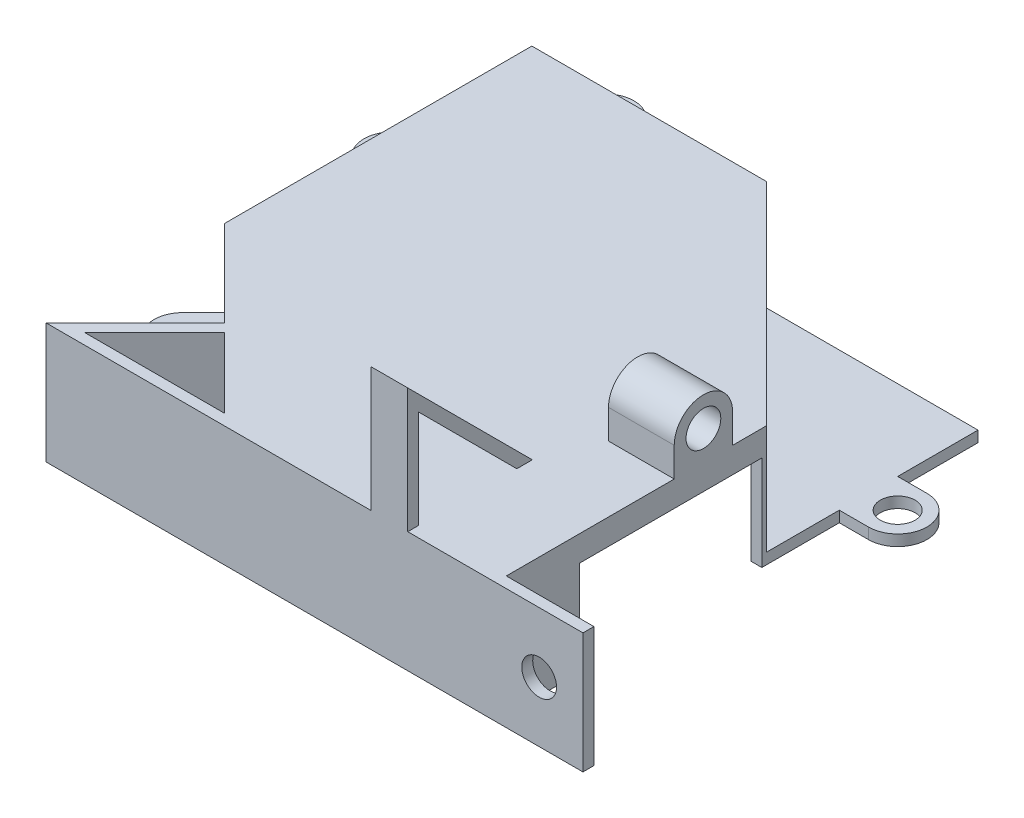
from build123d import *

# Parameters (mm, degrees)
SKETCH1_W            = 38
SKETCH1_H            = 1.5
SKETCH1_W_2          = 1.5
SKETCH1_H_2          = 32
SKETCH1_W_3          = 30
SKETCH1_H_3          = 40
BOSS_EXTRUDE1_DEPTH  = 15
BOSS_EXTRUDE2_DEPTH  = 1.5
SKETCH7_W            = 22
SKETCH7_H            = 12
BOSS_EXTRUDE4_DEPTH  = 10.5
SKETCH9_W            = 12.5
SKETCH9_H            = 8.5
CUT_EXTRUDE10_DEPTH  = 4.5
BOSS_EXTRUDE6_DEPTH  = 1.5
EXTRUDE_THIN1_START  = -20
EXTRUDE_THIN1_DEPTH  = 5
SKETCH16_W           = 10.5
SKETCH16_H           = 12
CUT_EXTRUDE15_DEPTH  = 35.121320344
BOSS_EXTRUDE10_DEPTH = 16
CUT_EXTRUDE16_DEPTH  = 34.560660172
SKETCH21_W           = 1.5
SKETCH21_H           = 25
CUT_EXTRUDE17_DEPTH  = 13
SKETCH25_W           = 1.5
SKETCH25_H           = 16.5
BOSS_EXTRUDE13_DEPTH = 12
BOSS_EXTRUDE14_DEPTH = 9
SKETCH27_R           = 2.38125
CUT_EXTRUDE18_DEPTH  = 6.35
SKETCH29_R           = 2.38125
CUT_EXTRUDE19_DEPTH  = 2.5
BOSS_EXTRUDE15_DEPTH = 9
BOSS_EXTRUDE16_DEPTH = 9
BOSS_EXTRUDE17_DEPTH = 9
BOSS_EXTRUDE18_DEPTH = 1.5
SKETCH34_R           = 2.38125
CUT_EXTRUDE20_DEPTH  = 34.560660172
SKETCH35_R           = 2.38125
CUT_EXTRUDE21_DEPTH  = 6.35


with BuildPart() as part:
    # Sketch1 → Boss-Extrude1 (new body)
    with BuildSketch(Plane(origin=(0, 0, 0), x_dir=(1, 0, 0), z_dir=(0, 1, 0))):
        Polygon((23.112698372, -23.112698372), (0, 0), (-1.060660172, -1.060660172), (10.2760191, -12.397339444), (11.408080409, -13.529400753), (20.991378029, -23.112698372), (22.0520382, -24.173358544), align=None)
        Polygon((23.112698372, -24.612698372), (23.112698372, -23.112698372), (22.0520382, -24.173358544), (22.491378029, -24.612698372), align=None)
        with Locations((42.112698372, -23.862698372)):
            Rectangle(SKETCH1_W, SKETCH1_H)
        with Locations((61.862698372, -23.862698372)):
            Rectangle(SKETCH1_W_2, SKETCH1_H)
        with Locations((61.862698372, -7.112698372)):
            Rectangle(SKETCH1_W_2, SKETCH1_H_2)
        Polygon((62.173358544, 9.9479618), (61.112698372, 8.887301628), (62.612698372, 8.887301628), (62.612698372, 9.508621971), align=None)
        Polygon((31.060660172, 41.060660172), (30, 40), (61.112698372, 8.887301628), (62.173358544, 9.9479618), align=None)
        Polygon((30, 41.5), (30, 40), (31.060660172, 41.060660172), (30.621320344, 41.5), align=None)
        with Locations((15, 40.75)):
            Rectangle(SKETCH1_W_3, SKETCH1_H)
        with Locations((-0.75, 40.75)):
            Rectangle(SKETCH1_W_2, SKETCH1_H)
        with Locations((-0.75, 20)):
            Rectangle(SKETCH1_W_2, SKETCH1_H_3)
        Polygon((-1.060660172, -1.060660172), (0, 0), (-1.5, 0), (-1.5, -0.621320344), align=None)
        Polygon((22.491378029, -24.612698372), (22.0520382, -24.173358544), (20.991378029, -23.112698372), (1.824782789, -23.112698372), (11.408080409, -13.529400753), (10.2760191, -12.397339444), (-1.939339828, -24.612698372), align=None)
    extrude(amount=BOSS_EXTRUDE1_DEPTH)

    # Sketch2 → Boss-Extrude2 (add)
    with BuildSketch(Plane(origin=(0, 15, 0), x_dir=(1, 0, 0), z_dir=(0, 1, 0))):
        Polygon((30.621320344, 41.5), (-1.5, 41.5), (-1.5, -0.621320344), (10.2760191, -12.397339444), (11.408080409, -13.529400753), (20.991378029, -23.112698372), (22.491378029, -24.612698372), (62.612698372, -24.612698372), (62.612698372, 9.508621971), align=None)
        Polygon((0, 40), (30, 40), (61.112698372, 8.887301628), (61.112698372, -23.112698372), (23.112698372, -23.112698372), (0, 0), align=None, mode=Mode.SUBTRACT)
        Polygon((30, 40), (61.112698372, 8.887301628), (61.112698372, -23.112698372), (23.112698372, -23.112698372), (0, 0), (0, 40), align=None)
        Polygon((11.408080409, -13.529400753), (10.2760191, -12.397339444), (-1.939339828, -24.612698372), (19.481361537, -24.612698372), (22.491378029, -24.612698372), (20.991378029, -23.112698372), (1.824782789, -23.112698372), align=None)
    extrude(amount=BOSS_EXTRUDE2_DEPTH)

    # Sketch7 → Boss-Extrude4 (add)
    with BuildSketch(Plane(origin=(62.612698372, 0, 0), x_dir=(0, 0, -1), z_dir=(1, 0, 0))):
        with Locations((-1.491378029, 6)):
            Rectangle(SKETCH7_W, SKETCH7_H)
    extrude(amount=BOSS_EXTRUDE4_DEPTH)

    # Sketch9 → Cut-Extrude10 (cut)
    with BuildSketch(Plane.ZY.offset(-61.112698372)):
        with Locations((1.362698372, 6.25)):
            Rectangle(SKETCH9_W, SKETCH9_H)
    extrude(amount=-CUT_EXTRUDE10_DEPTH, mode=Mode.SUBTRACT)

    # Sketch11 → Boss-Extrude6 (add)
    with BuildSketch(Plane.XZ):
        Polygon((62.612698372, -9.508621971), (30.621320344, -41.5), (62.612698372, -41.5), align=None)
    extrude(amount=-BOSS_EXTRUDE6_DEPTH)

    # Sketch12 → Extrude-Thin1 (add)
    with BuildSketch(Plane(origin=(62.612698372, 0, 0), x_dir=(0, 0, -1), z_dir=(1, 0, 0)).offset(EXTRUDE_THIN1_START)):
        Polygon((-7.5520382, 16.5), (-24.612698372, 33.560660172), (-24.612698372, 16.5), (-23.112698372, 16.5), (-23.112698372, 29.939339828), (-8.612698372, 15.439339828), align=None)
    extrude(amount=EXTRUDE_THIN1_DEPTH)

    # Sketch16 → Cut-Extrude15 (cut, through all)
    with BuildSketch(Plane(origin=(0, 0, -9.508621971), x_dir=(-1, 0, 0), z_dir=(0, 0, -1))):
        with Locations((-67.862698372, 6)):
            Rectangle(SKETCH16_W, SKETCH16_H)
    extrude(amount=-CUT_EXTRUDE15_DEPTH, mode=Mode.SUBTRACT)

    # Sketch19 → Boss-Extrude10 (add)
    with BuildSketch(Plane.XZ):
        Polygon((59.612698372, -10.387301628), (59.612698372, 23.112698372), (58.112698372, 23.112698372), (58.112698372, -11.887301628), align=None)
    extrude(amount=-BOSS_EXTRUDE10_DEPTH)

    # Sketch20 → Cut-Extrude16 (cut, through all)
    with BuildSketch(Plane.XZ):
        Polygon((59.612698372, 23.112698372), (59.612698372, 24.612698372), (62.612698372, 24.612698372), (62.612698372, -41.5), (59.612698372, -41.5), align=None)
    extrude(amount=-CUT_EXTRUDE16_DEPTH, mode=Mode.SUBTRACT)

    # Sketch21 → Cut-Extrude17 (cut)
    with BuildSketch(Plane.XZ):
        with Locations((58.862698372, 0.612698372)):
            Rectangle(SKETCH21_W, SKETCH21_H)
    extrude(amount=-CUT_EXTRUDE17_DEPTH, mode=Mode.SUBTRACT)

    # Sketch25 → Boss-Extrude13 (add)
    with BuildSketch(Plane(origin=(59.612698372, 0, 0), x_dir=(0, 0, -1), z_dir=(1, 0, 0))):
        with Locations((-23.862698372, 8.25)):
            Rectangle(SKETCH25_W, SKETCH25_H)
    extrude(amount=BOSS_EXTRUDE13_DEPTH)

    # Sketch26 → Boss-Extrude14 (add)
    with BuildSketch(Plane(origin=(59.612698372, 0, 0), x_dir=(0, 0, -1), z_dir=(1, 0, 0))):
        with BuildLine():
            Line((-0.112698372, 20.5), (-0.112698372, 16.5))
            Line((-0.112698372, 16.5), (3.887301628, 16.5))
            Line((3.887301628, 16.5), (7.887301628, 16.5))
            Line((7.887301628, 16.5), (7.887301628, 20.5))
            ThreePointArc((7.887301628, 20.5), (3.887301628, 24.5), (-0.112698372, 20.5))
        make_face()
    extrude(amount=-BOSS_EXTRUDE14_DEPTH)

    # Sketch27 → Cut-Extrude18 (cut)
    with BuildSketch(Plane(origin=(59.612698372, 0, 0), x_dir=(0, 0, -1), z_dir=(1, 0, 0))):
        with Locations((3.887301628, 20.5)):
            Circle(SKETCH27_R)
    extrude(amount=-CUT_EXTRUDE18_DEPTH, mode=Mode.SUBTRACT)

    # Sketch29 → Cut-Extrude19 (cut, through all)
    with BuildSketch(Plane(origin=(0, 0, 23.112698372), x_dir=(-1, 0, 0), z_dir=(0, 0, -1))):
        with Locations((-65.612698372, 8.25)):
            Circle(SKETCH29_R)
    extrude(amount=-CUT_EXTRUDE19_DEPTH, mode=Mode.SUBTRACT)

    # Sketch30 → Boss-Extrude15 (add)
    with BuildSketch(Plane.XZ):
        with BuildLine():
            Line((4.5, -41.5), (0.5, -41.5))
            Line((0.5, -41.5), (0.5, -45.5))
            ThreePointArc((0.5, -45.5), (4.5, -49.5), (8.5, -45.5))
            Line((8.5, -45.5), (8.5, -41.5))
            Line((8.5, -41.5), (4.5, -41.5))
        make_face()
    extrude(amount=-BOSS_EXTRUDE15_DEPTH)

    # Sketch31 → Boss-Extrude16 (add)
    with BuildSketch(Plane.XZ):
        with BuildLine():
            Line((-5.5, -30.5), (-1.5, -30.5))
            Line((-1.5, -30.5), (-1.5, -26.5))
            Line((-1.5, -26.5), (-1.5, -22.5))
            Line((-1.5, -22.5), (-5.5, -22.5))
            ThreePointArc((-5.5, -22.5), (-9.5, -26.5), (-5.5, -30.5))
        make_face()
    extrude(amount=-BOSS_EXTRUDE16_DEPTH)

    # Sketch32 → Boss-Extrude17 (add)
    with BuildSketch(Plane.XZ):
        with BuildLine():
            Line((-1.268844699, 6.509329894), (1.559582425, 3.680902769))
            Line((1.559582425, 3.680902769), (4.38800955, 6.509329894))
            Line((4.38800955, 6.509329894), (7.216436675, 9.337757018))
            Line((7.216436675, 9.337757018), (4.38800955, 12.166184143))
            ThreePointArc((4.38800955, 12.166184143), (-1.268844699, 12.166184143), (-1.268844699, 6.509329894))
        make_face()
    extrude(amount=-BOSS_EXTRUDE17_DEPTH)

    # Sketch33 → Boss-Extrude18 (add)
    with BuildSketch(Plane.XZ):
        with BuildLine():
            Line((59.612698372, -26.5), (59.612698372, -30.5))
            Line((59.612698372, -30.5), (63.612698372, -30.5))
            ThreePointArc((63.612698372, -30.5), (67.612698372, -26.5), (63.612698372, -22.5))
            Line((63.612698372, -22.5), (59.612698372, -22.5))
            Line((59.612698372, -22.5), (59.612698372, -26.5))
        make_face()
    extrude(amount=-BOSS_EXTRUDE18_DEPTH)

    # Sketch34 → Cut-Extrude20 (cut, through all)
    with BuildSketch(Plane.XZ):
        with Locations((63.612698372, -26.5)):
            Circle(SKETCH34_R)
    extrude(amount=-CUT_EXTRUDE20_DEPTH, mode=Mode.SUBTRACT)

    # Sketch35 → Cut-Extrude21 (cut)
    with BuildSketch(Plane.XZ):
        with Locations((4.5, -45.5)):
            Circle(SKETCH35_R)
        with Locations((-5.5, -26.5)):
            Circle(SKETCH35_R)
        with Locations((1.559582425, 9.337757018)):
            Circle(SKETCH35_R)
    extrude(amount=-CUT_EXTRUDE21_DEPTH, mode=Mode.SUBTRACT)


solid = part.part
